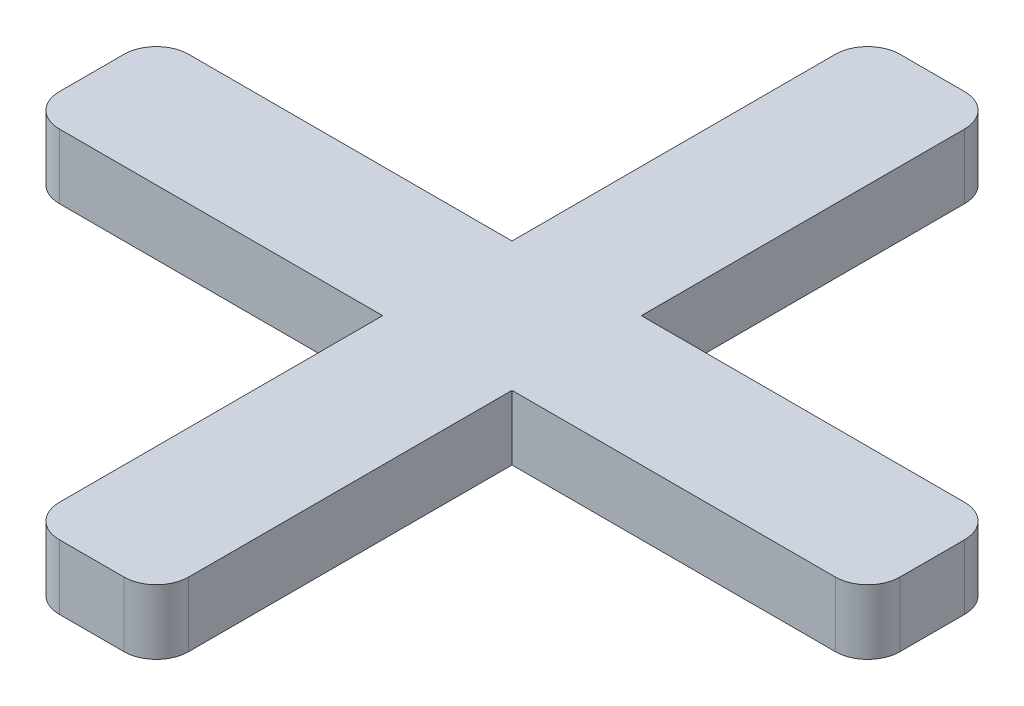
from build123d import *

# Parameters (mm, degrees)
BOSS_EXTRUDE1_DEPTH = 1


with BuildPart() as part:
    # Sketch2 → Boss-Extrude1 (new body)
    with BuildSketch(Plane(origin=(0, 0, 0), x_dir=(1, 0, 0), z_dir=(0, 1, 0))):
        with BuildLine():
            Line((-6, 1), (-1, 1))
            Line((-1, 1), (-1, 6))
            ThreePointArc((-1, 6), (-0.853553391, 6.353553391), (-0.5, 6.5))
            Line((-0.5, 6.5), (0.5, 6.5))
            ThreePointArc((0.5, 6.5), (0.853553391, 6.353553391), (1, 6))
            Line((1, 6), (1, 1))
            Line((1, 1), (6, 1))
            ThreePointArc((6, 1), (6.353553391, 0.853553391), (6.5, 0.5))
            Line((6.5, 0.5), (6.5, -0.5))
            ThreePointArc((6.5, -0.5), (6.353553391, -0.853553391), (6, -1))
            Line((6, -1), (1, -1))
            Line((1, -1), (1, -6))
            ThreePointArc((1, -6), (0.853553391, -6.353553391), (0.5, -6.5))
            Line((0.5, -6.5), (-0.5, -6.5))
            ThreePointArc((-0.5, -6.5), (-0.853553391, -6.353553391), (-1, -6))
            Line((-1, -6), (-1, -1))
            Line((-1, -1), (-6, -1))
            ThreePointArc((-6, -1), (-6.353553391, -0.853553391), (-6.5, -0.5))
            Line((-6.5, -0.5), (-6.5, 0.5))
            ThreePointArc((-6.5, 0.5), (-6.353553391, 0.853553391), (-6, 1))
        make_face()
    extrude(amount=BOSS_EXTRUDE1_DEPTH)


solid = part.part
